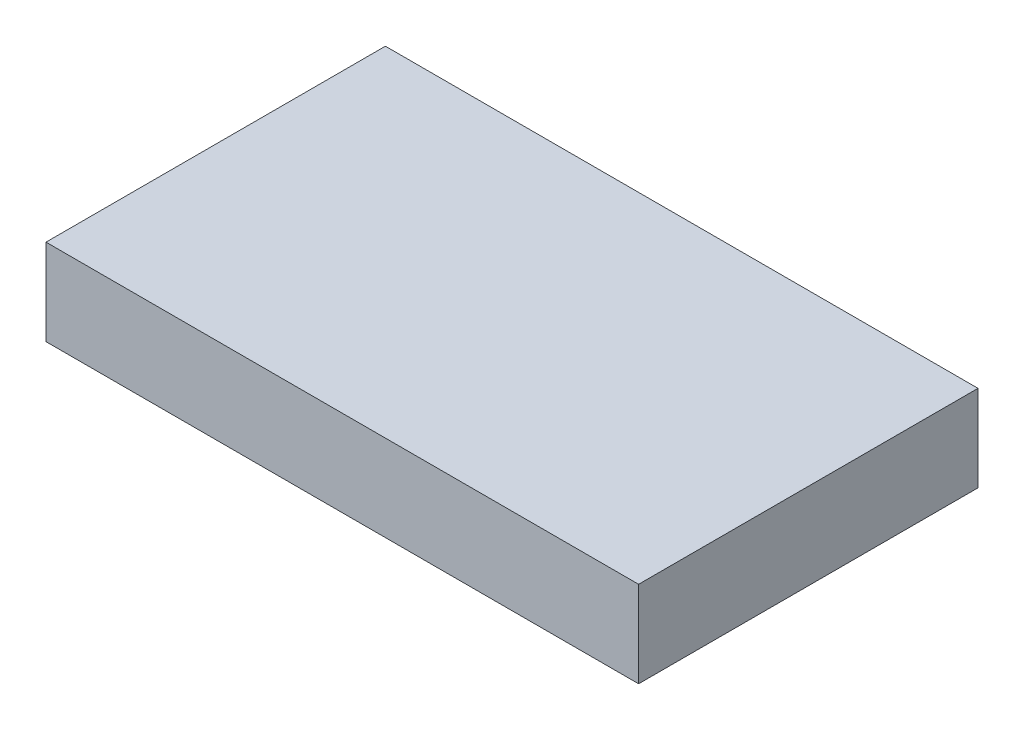
from build123d import *

# Parameters (mm, degrees)
SKETCH1_W           = 18.9
SKETCH1_H           = 4.8
BOSS_EXTRUDE1_DEPTH = 33


with BuildPart() as part:
    # Sketch1 → Boss-Extrude1 (new body)
    with BuildSketch(Plane(origin=(0, 0, 0), x_dir=(0, 0, -1), z_dir=(1, 0, 0))):
        with Locations((0, 2.4)):
            Rectangle(SKETCH1_W, SKETCH1_H)
    extrude(amount=BOSS_EXTRUDE1_DEPTH)


solid = part.part
